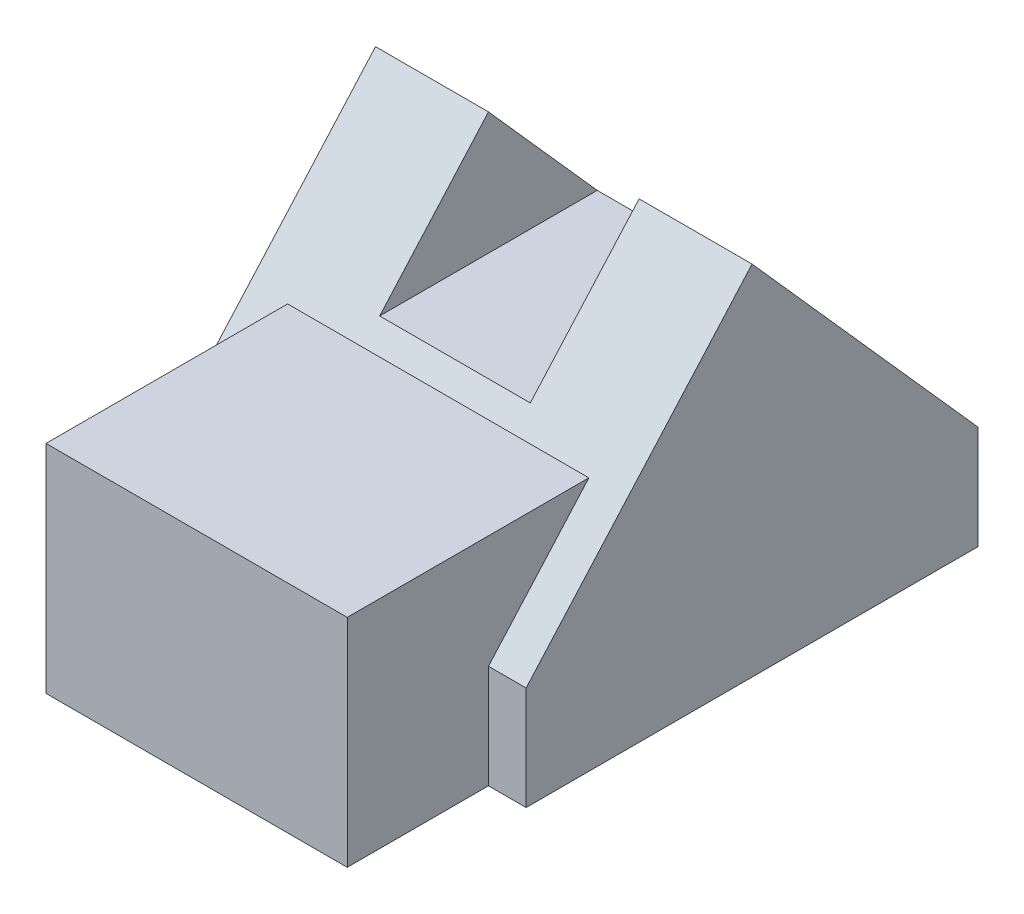
from build123d import *

# Parameters (mm, degrees)
CROQUIS1_W              = 40
CROQUIS1_H              = 63
SALIENTE_EXTRUIR1_DEPTH = 38
CROQUIS2_W              = 4
CROQUIS2_H              = 15
CORTAR_EXTRUIR1_DEPTH   = 38
CORTAR_EXTRUIR2_DEPTH   = 4
CORTAR_EXTRUIR14_DEPTH  = 60
CORTAR_EXTRUIR15_DEPTH  = 40
CROQUIS20_W             = 25.666666667
CROQUIS20_H             = 15
CROQUIS20_W_2           = 10.666666667
CORTAR_EXTRUIR16_DEPTH  = 40
CROQUIS22_W             = 16
CROQUIS22_H             = 13
CORTAR_EXTRUIR17_DEPTH  = 72
CORTAR_EXTRUIR19_DEPTH  = 40
SALIENTE_EXTRUIR2_DEPTH = 36
CORTAR_EXTRUIR20_DEPTH  = 4


with BuildPart() as part:
    # Croquis1 → Saliente-Extruir1 (new body)
    with BuildSketch(Plane(origin=(0, 0, 0), x_dir=(1, 0, 0), z_dir=(0, 1, 0))):
        with Locations((20, 31.5)):
            Rectangle(CROQUIS1_W, CROQUIS1_H)
    extrude(amount=SALIENTE_EXTRUIR1_DEPTH)

    # Croquis2 → Cortar-Extruir1 (cut)
    with BuildSketch(Plane(origin=(0, 38, 0), x_dir=(1, 0, 0), z_dir=(0, 1, 0))):
        with Locations((2, 7.5)):
            Rectangle(CROQUIS2_W, CROQUIS2_H)
        with Locations((38, 7.5)):
            Rectangle(CROQUIS2_W, CROQUIS2_H)
    extrude(amount=-CORTAR_EXTRUIR1_DEPTH, mode=Mode.SUBTRACT)

    # Croquis5 → Cortar-Extruir2 (cut)
    with BuildSketch(Plane(origin=(40, 0, 0), x_dir=(0, 0, -1), z_dir=(1, 0, 0))):
        Polygon((15, 38), (15, 11), (39, 38), align=None)
        Polygon((63, 38), (39, 38), (63, 11), align=None)
    extrude(amount=-CORTAR_EXTRUIR2_DEPTH, mode=Mode.SUBTRACT)

    # Croquis11 → Cortar-Extruir14 (cut)
    with BuildSketch(Plane(origin=(40, 0, 0), x_dir=(0, 0, -1), z_dir=(1, 0, 0))):
        Polygon((39, 38), (52.333333333, 23), (52.333333333, 38), align=None)
    extrude(amount=-CORTAR_EXTRUIR14_DEPTH, mode=Mode.SUBTRACT)

    # Croquis19 → Cortar-Extruir15 (cut)
    with BuildSketch(Plane(origin=(40, 0, 0), x_dir=(0, 0, -1), z_dir=(1, 0, 0))):
        Polygon((25.666666667, 23), (39, 38), (25.666666667, 38), align=None)
    extrude(amount=-CORTAR_EXTRUIR15_DEPTH, mode=Mode.SUBTRACT)

    # Croquis20 → Cortar-Extruir16 (cut)
    with BuildSketch(Plane(origin=(40, 0, 0), x_dir=(0, 0, -1), z_dir=(1, 0, 0))):
        with Locations((12.833333334, 30.5)):
            Rectangle(CROQUIS20_W, CROQUIS20_H)
        with Locations((57.666666667, 30.5)):
            Rectangle(CROQUIS20_W_2, CROQUIS20_H)
    extrude(amount=-CORTAR_EXTRUIR16_DEPTH, mode=Mode.SUBTRACT)

    # Croquis22 → Cortar-Extruir17 (cut)
    with BuildSketch(Plane.XY):
        with Locations((20, 31.5)):
            Rectangle(CROQUIS22_W, CROQUIS22_H)
    extrude(amount=-CORTAR_EXTRUIR17_DEPTH, mode=Mode.SUBTRACT)

    # Croquis23 → Cortar-Extruir19 (cut)
    with BuildSketch(Plane.ZY):
        Polygon((-63, 23), (-63, 11), (-52.333333333, 23), align=None)
        Polygon((-25.666666667, 23), (-15, 11), (-15, 23), align=None)
    extrude(amount=-CORTAR_EXTRUIR19_DEPTH, mode=Mode.SUBTRACT)

    # Croquis24 → Saliente-Extruir2 (add)
    with BuildSketch(Plane.ZY):
        Polygon((-15, 11), (-15, 23), (-25.666666667, 23), align=None)
    extrude(amount=-SALIENTE_EXTRUIR2_DEPTH)

    # Croquis26 → Cortar-Extruir20 (cut)
    with BuildSketch(Plane.ZY):
        Polygon((-15, 23), (-25.666666667, 23), (-15, 11), align=None)
    extrude(amount=-CORTAR_EXTRUIR20_DEPTH, mode=Mode.SUBTRACT)


solid = part.part
